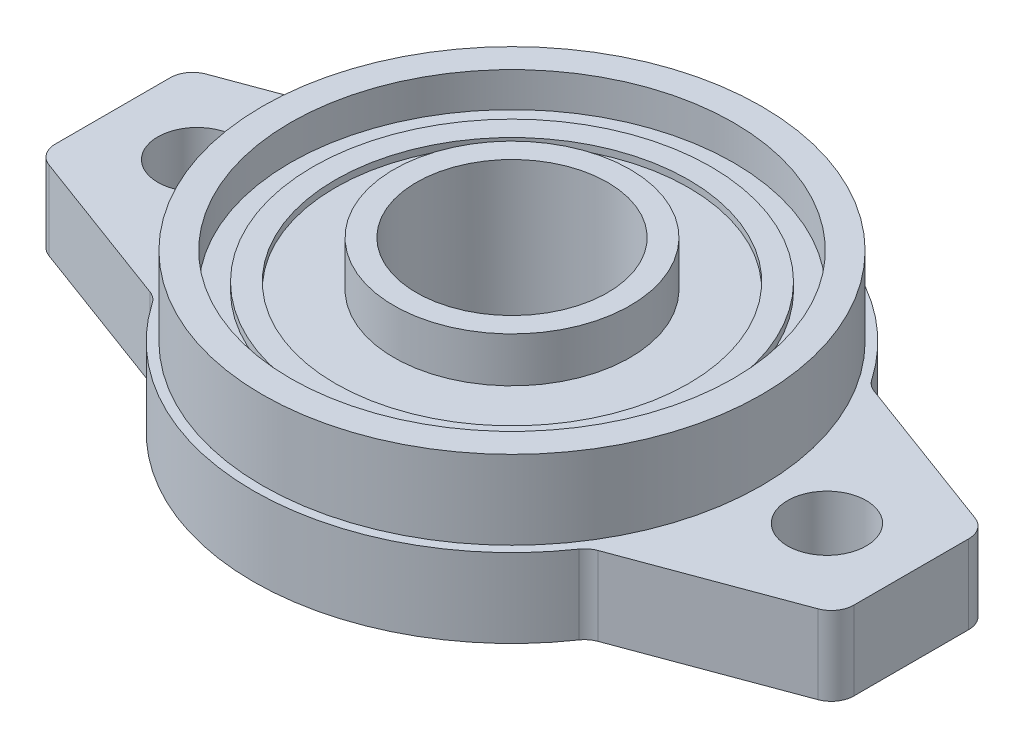
from build123d import *

# Parameters (mm, degrees)
SKETCH1_R           = 3.5
SKETCH1_R_2         = 8.5
BOSS_EXTRUDE1_DEPTH = 7


with BuildPart() as part:
    # Sketch1 → Boss-Extrude1 (new body)
    with BuildSketch(Plane(origin=(0, 0, 0), x_dir=(1, 0, 0), z_dir=(0, 1, 0))):
        with BuildLine():
            Line((19.915308817, 12.274508393), (34.194882732, 6.983577796))
            ThreePointArc((34.194882732, 6.983577796), (35.141609799, 6.250591667), (35.5, 5.108174376))
            Line((35.5, 5.108174376), (35.5, -5.108174376))
            ThreePointArc((35.5, -5.108174376), (35.141609799, -6.250591667), (34.194882732, -6.983577796))
            Line((34.194882732, -6.983577796), (19.915308817, -12.274508393))
            ThreePointArc((19.915308817, -12.274508393), (19.380803519, -12.572380491), (18.961376225, -13.017918868))
            ThreePointArc((18.961376225, -13.017918868), (0, -23), (-18.961376225, -13.017918868))
            ThreePointArc((-18.961376225, -13.017918868), (-19.380803519, -12.572380491), (-19.915308817, -12.274508393))
            Line((-19.915308817, -12.274508393), (-34.194882732, -6.983577796))
            ThreePointArc((-34.194882732, -6.983577796), (-35.141609799, -6.250591667), (-35.5, -5.108174376))
            Line((-35.5, -5.108174376), (-35.5, 5.108174376))
            ThreePointArc((-35.5, 5.108174376), (-35.141609799, 6.250591667), (-34.194882732, 6.983577796))
            Line((-34.194882732, 6.983577796), (-19.915308817, 12.274508393))
            ThreePointArc((-19.915308817, 12.274508393), (-19.380803519, 12.572380491), (-18.961376225, 13.017918868))
            ThreePointArc((-18.961376225, 13.017918868), (0, 23), (18.961376225, 13.017918868))
            ThreePointArc((18.961376225, 13.017918868), (19.380803519, 12.572380491), (19.915308817, 12.274508393))
        make_face()
        with Locations((28, 0)):
            Circle(SKETCH1_R, mode=Mode.SUBTRACT)
        with Locations((-28, 0)):
            Circle(SKETCH1_R, mode=Mode.SUBTRACT)
        Circle(SKETCH1_R_2, mode=Mode.SUBTRACT)
    extrude(amount=BOSS_EXTRUDE1_DEPTH)

    # Sketch2 → Revolve1 (revolve)
    with BuildSketch(Plane.XY):
        Polygon((-8.5, 15), (-8.5, 7), (-22.2, 7), (-22.2, 14), (-19.7, 14), (-19.7, 10.918286082), (-17.7, 10.918286082), (-17.7, 11.6), (-15.7, 11.6), (-15.7, 11), (-10.5, 11), (-10.5, 15), align=None)
    revolve(axis=Axis((0, 0, 0), (0, 1, 0)))


solid = part.part
